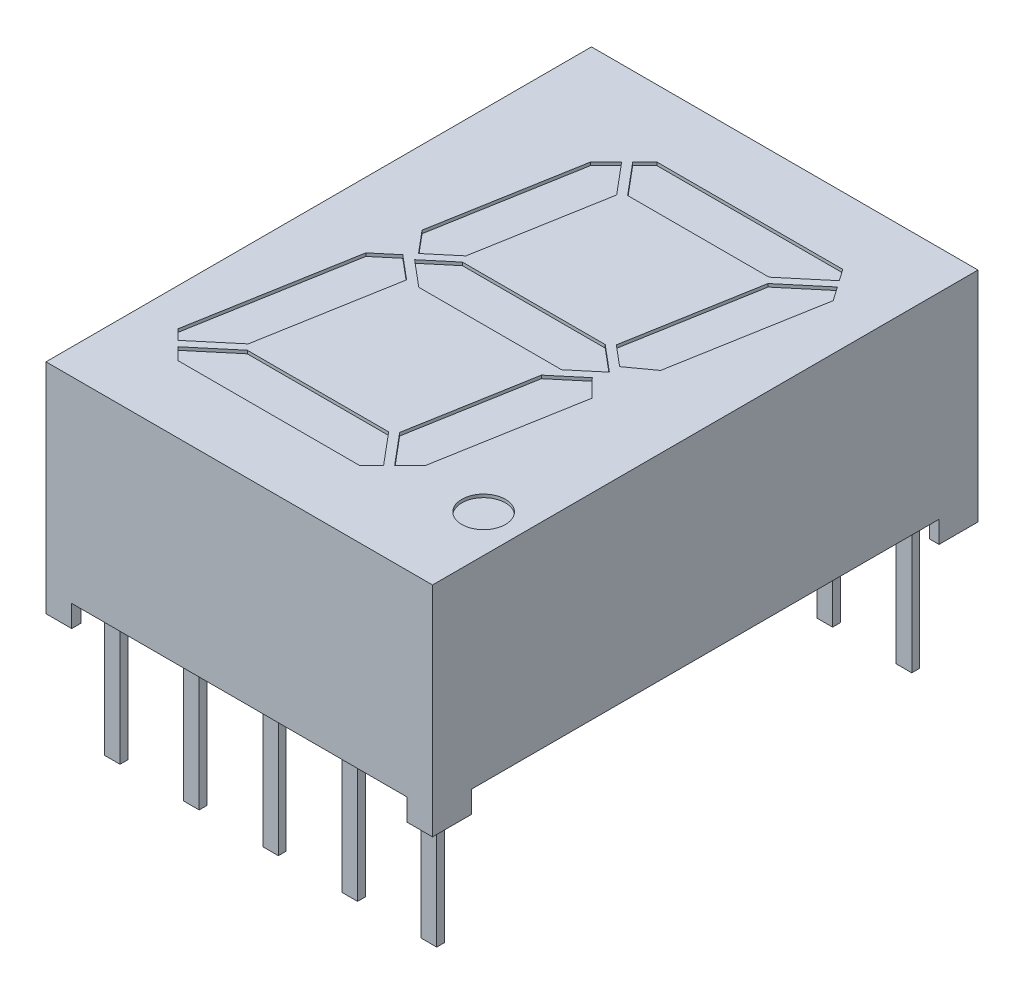
from build123d import *

# Parameters (mm, degrees)
SKETCH1_W          = 12.4
SKETCH1_H          = 17.5
EXTRUDE2_DEPTH     = 7
SKETCH2_W          = 5.375
SKETCH2_H          = 0.7
CUT_EXTRUDE2_DEPTH = 20.841622917
SKETCH3_W          = 15
SKETCH3_H          = 0.7
CUT_EXTRUDE3_DEPTH = 17.712944085
SKETCH6_R          = 0.7
CUT_EXTRUDE4_DEPTH = 0.1
SKETCH7_W          = 0.525
SKETCH7_H          = 0.95
CUT_EXTRUDE6_DEPTH = 0.7
SKETCH7_3_W        = 0.5
SKETCH7_3_H        = 0.25
EXTRUDE3_DEPTH     = 0.7
SKETCH7_4_W        = 0.525
SKETCH7_4_H        = 0.95
SKETCH7_4_W_2      = 0.5
SKETCH7_4_H_2      = 0.25
EXTRUDE4_DEPTH     = 4
SKETCH8_W          = 0.025316456
SKETCH8_H          = 0.026582279
CUT_EXTRUDE7_DEPTH = 0.01


with BuildPart() as part:
    # Sketch1 → Extrude2 (new body)
    with BuildSketch(Plane(origin=(0, 0, 0), x_dir=(1, 0, 0), z_dir=(0, 1, 0))):
        Rectangle(SKETCH1_W, SKETCH1_H)
    extrude(amount=-EXTRUDE2_DEPTH)

    # Sketch2 → Cut-Extrude2 (cut, through all)
    with BuildSketch(Plane.XY.offset(8.75)):
        with Locations((-2.6875, -6.65)):
            Rectangle(SKETCH2_W, SKETCH2_H)
        with Locations((2.6875, -6.65)):
            Rectangle(SKETCH2_W, SKETCH2_H)
    extrude(amount=-CUT_EXTRUDE2_DEPTH, mode=Mode.SUBTRACT)

    # Sketch3 → Cut-Extrude3 (cut, through all)
    with BuildSketch(Plane(origin=(6.2, 0, 0), x_dir=(0, 0, -1), z_dir=(1, 0, 0))):
        with Locations((0, -6.65)):
            Rectangle(SKETCH3_W, SKETCH3_H)
    extrude(amount=-CUT_EXTRUDE3_DEPTH, mode=Mode.SUBTRACT)

    # Sketch6 → Cut-Extrude4 (cut)
    with BuildSketch(Plane(origin=(0, 0, 0), x_dir=(-1, 0, 0), z_dir=(0, 1, 0))):
        Polygon((2.518570273, -6.036238766), (3.015469211, -5.539339828), (3.826241837, -0.941219775), (3.233742238, -0.23510625), (2.406800539, -0.928992725), (1.682041921, -5.039303098), align=None)
        Polygon((-4.011585774, -6.6), (1.954809039, -6.6), (2.341118319, -6.21369072), (1.49053081, -5.2), (-3.046184069, -5.2), (-4.271783106, -6.228399699), align=None)
        Polygon((3.45258656, 0.051474061), (4.096560254, 0.59183215), (5.000109846, 5.716116524), (4.679337781, 6.036888588), (3.453738745, 5.008488889), (2.692188648, 0.689523668), align=None)
        Polygon((-4.728556319, -5.576059945), (-4.415724957, -6.022829431), (-3.206880972, -5.008488889), (-2.477147485, -0.869964629), (-3.135471532, -0.317565164), (-3.898516777, -0.868671778), align=None)
        Polygon((2.290772485, -0.7), (3.125, 0), (2.290772485, 0.7), (-2.290772485, 0.7), (-3.125, 0), (-2.290772485, -0.7), align=None)
        Polygon((3.293041842, 5.2), (4.501885827, 6.214340542), (4.116226369, 6.6), (-1.707951266, 6.6), (-2.094260546, 6.21369072), (-1.243673037, 5.2), align=None)
        Polygon((-2.768611438, 5.539339828), (-3.567463069, 1.008827096), (-3.003440318, 0.428352507), (-2.117076363, 1.172100174), (-1.435184148, 5.039303098), (-2.2717125, 6.036238766), align=None)
        with Locations(Location((-4.989453029, 5.9, 0), (0, 0, 90))):
            Circle(SKETCH6_R)
    extrude(amount=-CUT_EXTRUDE4_DEPTH, mode=Mode.SUBTRACT)

    # Sketch7 → Cut-Extrude6 (cut)
    with BuildSketch(Plane.XZ.offset(7)):
        with Locations((-5.6375, 7.975)):
            Rectangle(SKETCH7_W, SKETCH7_H)
        with Locations((-5.6375, -7.975)):
            Rectangle(SKETCH7_W, SKETCH7_H)
        with Locations((5.6375, -7.975)):
            Rectangle(SKETCH7_W, SKETCH7_H)
        with Locations((5.6375, 7.975)):
            Rectangle(SKETCH7_W, SKETCH7_H)
    extrude(amount=-CUT_EXTRUDE6_DEPTH, mode=Mode.SUBTRACT)

    # Sketch7_3 → Extrude3 (add)
    with BuildSketch(Plane.XZ.offset(7)):
        with Locations((-5.08, 7.62)):
            Rectangle(SKETCH7_3_W, SKETCH7_3_H)
        with Locations((-2.54, 7.62)):
            Rectangle(SKETCH7_3_W, SKETCH7_3_H)
        with Locations((0, 7.62)):
            Rectangle(SKETCH7_3_W, SKETCH7_3_H)
        with Locations((2.54, 7.62)):
            Rectangle(SKETCH7_3_W, SKETCH7_3_H)
        with Locations((5.08, 7.62)):
            Rectangle(SKETCH7_3_W, SKETCH7_3_H)
        with Locations((5.08, -7.62)):
            Rectangle(SKETCH7_3_W, SKETCH7_3_H)
        with Locations((0, -7.62)):
            Rectangle(SKETCH7_3_W, SKETCH7_3_H)
        with Locations((2.54, -7.62)):
            Rectangle(SKETCH7_3_W, SKETCH7_3_H)
        with Locations((-2.54, -7.62)):
            Rectangle(SKETCH7_3_W, SKETCH7_3_H)
        with Locations((-5.08, -7.62)):
            Rectangle(SKETCH7_3_W, SKETCH7_3_H)
    extrude(amount=-EXTRUDE3_DEPTH)


with BuildPart() as extrude4_tool:
    # Sketch7_4 → Extrude4 (new body)
    with BuildSketch(Plane.XZ.offset(7)):
        with Locations((-5.6375, 7.975)):
            Rectangle(SKETCH7_4_W, SKETCH7_4_H)
        with Locations((-5.6375, -7.975)):
            Rectangle(SKETCH7_4_W, SKETCH7_4_H)
        with Locations((5.6375, -7.975)):
            Rectangle(SKETCH7_4_W, SKETCH7_4_H)
        with Locations((5.6375, 7.975)):
            Rectangle(SKETCH7_4_W, SKETCH7_4_H)
        with Locations((-5.08, 7.62)):
            Rectangle(SKETCH7_4_W_2, SKETCH7_4_H_2)
        with Locations((-2.54, 7.62)):
            Rectangle(SKETCH7_4_W_2, SKETCH7_4_H_2)
        with Locations((0, 7.62)):
            Rectangle(SKETCH7_4_W_2, SKETCH7_4_H_2)
        with Locations((2.54, 7.62)):
            Rectangle(SKETCH7_4_W_2, SKETCH7_4_H_2)
        with Locations((5.08, 7.62)):
            Rectangle(SKETCH7_4_W_2, SKETCH7_4_H_2)
        with Locations((5.08, -7.62)):
            Rectangle(SKETCH7_4_W_2, SKETCH7_4_H_2)
        with Locations((0, -7.62)):
            Rectangle(SKETCH7_4_W_2, SKETCH7_4_H_2)
        with Locations((2.54, -7.62)):
            Rectangle(SKETCH7_4_W_2, SKETCH7_4_H_2)
        with Locations((-2.54, -7.62)):
            Rectangle(SKETCH7_4_W_2, SKETCH7_4_H_2)
        with Locations((-5.08, -7.62)):
            Rectangle(SKETCH7_4_W_2, SKETCH7_4_H_2)
    extrude(amount=EXTRUDE4_DEPTH)


with BuildPart() as part_1:
    add(part.part)


with BuildPart() as part_2:
    # Extrude4: joined with extrude4_tool
    add(part_1.part.fuse(extrude4_tool.part, tol=0.00001))


with BuildPart() as extrude4_kept_piece:
    # of the separate pieces the step leaves, the one the design keeps (extrude4_pieces_kept)
    add(part_2.part.solids().sort_by_distance((-6.2, 0, -8.75))[0])

    # Sketch8 → Cut-Extrude7 (cut)
    with BuildSketch(Plane.XZ.offset(6.3)):
        Polygon((-0.572151899, -6.278449642), (-0.595609177, -6.353133186), (-0.620352057, -6.353133186), (-0.636768196, -6.302796952), (-0.652294304, -6.353133186), (-0.678026108, -6.353133186), (-0.701265823, -6.278449642), (-0.676087816, -6.278449642), (-0.663093354, -6.329933028), (-0.646677215, -6.278449642), (-0.625178006, -6.278449642), (-0.608860759, -6.329933028), (-0.596044304, -6.278449642), align=None)
        Polygon((-0.437974684, -6.278449642), (-0.461431962, -6.353133186), (-0.486174842, -6.353133186), (-0.502590981, -6.302796952), (-0.518117089, -6.353133186), (-0.543848892, -6.353133186), (-0.567088608, -6.278449642), (-0.541910601, -6.278449642), (-0.528916139, -6.329933028), (-0.5125, -6.278449642), (-0.491000791, -6.278449642), (-0.474683544, -6.329933028), (-0.461867089, -6.278449642), align=None)
        Polygon((-0.303797468, -6.278449642), (-0.327254747, -6.353133186), (-0.351997627, -6.353133186), (-0.368413766, -6.302796952), (-0.383939873, -6.353133186), (-0.409671677, -6.353133186), (-0.432911392, -6.278449642), (-0.407733386, -6.278449642), (-0.394738924, -6.329933028), (-0.378322785, -6.278449642), (-0.356823576, -6.278449642), (-0.340506329, -6.329933028), (-0.327689873, -6.278449642), align=None)
        with Locations((-0.275949367, -6.339842047)):
            Rectangle(SKETCH8_W, SKETCH8_H)
        with BuildLine():
            add(Edge.make_bspline(
                [(-0.159493671, -6.3219623), (-0.15953016, -6.323184441), (-0.159601812, -6.325584319), (-0.16021153, -6.329091898), (-0.161205016, -6.332416603), (-0.162579134, -6.335579263), (-0.164367936, -6.338557882), (-0.166577526, -6.341338159), (-0.169141939, -6.343972959), (-0.172108149, -6.346379089), (-0.175388259, -6.348583466), (-0.178985835, -6.350480465), (-0.182864539, -6.352076948), (-0.187013125, -6.353415499), (-0.191459564, -6.35440408), (-0.196177094, -6.355128025), (-0.201170512, -6.355601355), (-0.20459409, -6.355643321), (-0.206348892, -6.355664831)],
                knots=[0, 0, 0, 0, 0.907352243, 1.781736951, 2.63548328, 3.47985091, 4.336556021, 5.208523475, 6.112432747, 7.062451073, 8.040435374, 9.043840564, 10.077958095, 11.152835584, 12.277940427, 13.457536469, 14.696825396, 16, 16, 16, 16], degree=3))
            add(Edge.make_bspline(
                [(-0.206348892, -6.355664831), (-0.208367148, -6.35564076), (-0.21227633, -6.355594135), (-0.217939855, -6.355165536), (-0.223207892, -6.354519396), (-0.228103607, -6.353552855), (-0.232708206, -6.35235209), (-0.237141474, -6.351060798), (-0.241422786, -6.349596382), (-0.244195876, -6.348496225), (-0.24556962, -6.347951224)],
                knots=[0, 0, 0, 0, 1.203215828, 2.33052265, 3.384689099, 4.366106119, 5.303329643, 6.221311756, 7.118865988, 8, 8, 8, 8], degree=3))
            Line((-0.24556962, -6.347951224), (-0.24556962, -6.324019262))
            Line((-0.24556962, -6.324019262), (-0.242721519, -6.324019262))
            add(Edge.make_bspline(
                [(-0.242721519, -6.324019262), (-0.241356205, -6.325100717), (-0.238633592, -6.327257278), (-0.234200359, -6.330019883), (-0.229552713, -6.332422046), (-0.224707243, -6.334396048), (-0.219810398, -6.335982372), (-0.21493502, -6.337075899), (-0.210169433, -6.337823248), (-0.207010864, -6.337903755), (-0.205458861, -6.337943312)],
                knots=[0, 0, 0, 0, 1.030622468, 2.055194264, 3.087043286, 4.125157485, 5.149848264, 6.130935704, 7.081611712, 8, 8, 8, 8], degree=3))
            add(Edge.make_bspline(
                [(-0.205458861, -6.337943312), (-0.205030085, -6.337942389), (-0.204112108, -6.337940412), (-0.202650581, -6.337812684), (-0.20099877, -6.337717108), (-0.199226261, -6.337509923), (-0.197429535, -6.337288063), (-0.195767134, -6.336913138), (-0.194257539, -6.33654827), (-0.193351018, -6.336180273), (-0.192919304, -6.336005021)],
                knots=[0, 0, 0, 0, 0.806402781, 1.726445712, 2.758724871, 3.919014682, 5.083870887, 6.16165551, 7.124521387, 8, 8, 8, 8], degree=3))
            add(Edge.make_bspline(
                [(-0.192919304, -6.336005021), (-0.192439741, -6.335776879), (-0.191497298, -6.335328532), (-0.190203698, -6.334518214), (-0.189036018, -6.333634749), (-0.187978647, -6.332669818), (-0.187104366, -6.331504068), (-0.186480499, -6.330095395), (-0.186135606, -6.328446377), (-0.186096583, -6.327271174), (-0.186075949, -6.3266498)],
                knots=[0, 0, 0, 0, 1.024747072, 2.013846092, 2.940605744, 3.850156746, 4.769278501, 5.73222711, 6.800942666, 8, 8, 8, 8], degree=3))
            add(Edge.make_bspline(
                [(-0.186075949, -6.3266498), (-0.186107794, -6.326104162), (-0.18617041, -6.325031279), (-0.186747603, -6.323496164), (-0.187657041, -6.322086996), (-0.188938631, -6.320818221), (-0.190531807, -6.319668688), (-0.192474191, -6.318686382), (-0.194724312, -6.317813195), (-0.196368382, -6.317395217), (-0.197231013, -6.317175907)],
                knots=[0, 0, 0, 0, 0.82557554, 1.623324704, 2.456147571, 3.35491006, 4.343819762, 5.427079081, 6.650009487, 8, 8, 8, 8], degree=3))
            add(Edge.make_bspline(
                [(-0.197231013, -6.317175907), (-0.199199639, -6.316727667), (-0.203238649, -6.315808017), (-0.209388473, -6.314669263), (-0.215516824, -6.313394403), (-0.219469591, -6.31218776), (-0.221400316, -6.311598376)],
                knots=[0, 0, 0, 0, 0.976100998, 2.002656142, 3.024398856, 4, 4, 4, 4], degree=3))
            add(Edge.make_bspline(
                [(-0.221400316, -6.311598376), (-0.222438835, -6.311245386), (-0.224460408, -6.310558258), (-0.227351919, -6.309396597), (-0.230013147, -6.308126768), (-0.23245286, -6.306771213), (-0.234653549, -6.305298673), (-0.236647817, -6.303757295), (-0.238410933, -6.302117256), (-0.239957738, -6.300377489), (-0.241282641, -6.298526787), (-0.242435025, -6.296581589), (-0.243417646, -6.294526169), (-0.244195684, -6.292355947), (-0.244820323, -6.290082291), (-0.245239305, -6.287704579), (-0.245538322, -6.28522145), (-0.245559046, -6.283527065), (-0.24556962, -6.282662458)],
                knots=[0, 0, 0, 0, 1.287047841, 2.5053592, 3.654260482, 4.74538952, 5.777514103, 6.75871007, 7.700244599, 8.599107454, 9.48590269, 10.366941872, 11.24940663, 12.154970331, 13.068988358, 14.012872203, 14.986013017, 16, 16, 16, 16], degree=3))
            add(Edge.make_bspline(
                [(-0.24556962, -6.282662458), (-0.245532318, -6.281506313), (-0.245458909, -6.279231041), (-0.24485748, -6.275901997), (-0.24383089, -6.27275326), (-0.242444827, -6.269749797), (-0.240616199, -6.266936711), (-0.238431404, -6.264258164), (-0.235807357, -6.261786572), (-0.232830235, -6.259486238), (-0.229542851, -6.25740684), (-0.226003867, -6.255576284), (-0.222234578, -6.254039632), (-0.218249032, -6.252765738), (-0.214030563, -6.251811067), (-0.20959333, -6.251092136), (-0.204919541, -6.250678954), (-0.20172812, -6.250627704), (-0.200098892, -6.25060154)],
                knots=[0, 0, 0, 0, 0.894990994, 1.761326291, 2.609044902, 3.454222546, 4.315366365, 5.200560057, 6.125081389, 7.100429509, 8.110379559, 9.133447974, 10.182136699, 11.259192205, 12.370181258, 13.528580438, 14.738335141, 16, 16, 16, 16], degree=3))
            add(Edge.make_bspline(
                [(-0.200098892, -6.25060154), (-0.198430198, -6.250623693), (-0.19509564, -6.250667961), (-0.1901143, -6.251046518), (-0.185159872, -6.25159883), (-0.180297448, -6.25244807), (-0.175605285, -6.253416302), (-0.17118617, -6.254515575), (-0.167106618, -6.255753082), (-0.164532965, -6.256707483), (-0.163291139, -6.257167996)],
                knots=[0, 0, 0, 0, 1.065407564, 2.129008667, 3.188544425, 4.247469455, 5.279542408, 6.247502114, 7.154394069, 8, 8, 8, 8], degree=3))
            Line((-0.163291139, -6.257167996), (-0.163291139, -6.279715464))
            Line((-0.163291139, -6.279715464), (-0.166119462, -6.279715464))
            add(Edge.make_bspline(
                [(-0.166119462, -6.279715464), (-0.167192966, -6.278916177), (-0.169383743, -6.277285011), (-0.173033347, -6.275183275), (-0.177000967, -6.273243184), (-0.181282594, -6.271551527), (-0.185742374, -6.27009352), (-0.190325133, -6.269073962), (-0.194951348, -6.268432254), (-0.198053052, -6.268359466), (-0.19960443, -6.268323059)],
                knots=[0, 0, 0, 0, 0.892265782, 1.820912499, 2.804518821, 3.836954028, 4.889985052, 5.931488012, 6.965393252, 8, 8, 8, 8], degree=3))
            add(Edge.make_bspline(
                [(-0.19960443, -6.268323059), (-0.200700035, -6.268344962), (-0.202897679, -6.268388896), (-0.20616687, -6.268773782), (-0.209407348, -6.269412634), (-0.21144203, -6.270228686), (-0.212460443, -6.270637142)],
                knots=[0, 0, 0, 0, 0.999122297, 2.004111588, 3.001004448, 4, 4, 4, 4], degree=3))
            add(Edge.make_bspline(
                [(-0.212460443, -6.270637142), (-0.212894173, -6.270838321), (-0.213761342, -6.271240544), (-0.214968884, -6.27202017), (-0.216089856, -6.272936513), (-0.217085439, -6.27398927), (-0.217929873, -6.275157624), (-0.218548899, -6.276425207), (-0.218923392, -6.277789088), (-0.218965739, -6.278724187), (-0.218987342, -6.279201224)],
                knots=[0, 0, 0, 0, 1.004925302, 2.009180302, 3.014392739, 4.04465309, 5.049195417, 6.035570224, 6.99785458, 8, 8, 8, 8], degree=3))
            add(Edge.make_bspline(
                [(-0.218987342, -6.279201224), (-0.218952904, -6.279839389), (-0.218887095, -6.281058865), (-0.218280511, -6.282774661), (-0.217295678, -6.284253095), (-0.216135073, -6.285248015), (-0.215017943, -6.285945453), (-0.213982284, -6.286455963), (-0.212773057, -6.286939322), (-0.211401809, -6.287436791), (-0.209865482, -6.287927978), (-0.208156925, -6.288403525), (-0.206274208, -6.288852821), (-0.204958333, -6.289139011), (-0.204272152, -6.289288249)],
                knots=[0, 0, 0, 0, 1.173816843, 2.243057204, 3.312297565, 4.415174738, 5.03266065, 5.73970059, 6.541434878, 7.433956553, 8.430083051, 9.515931566, 10.70464786, 12, 12, 12, 12], degree=3))
            add(Edge.make_bspline(
                [(-0.204272152, -6.289288249), (-0.202439229, -6.289663694), (-0.198844263, -6.290400065), (-0.193445039, -6.29151243), (-0.187940051, -6.292777789), (-0.184268899, -6.293929785), (-0.182357595, -6.294529547)],
                knots=[0, 0, 0, 0, 0.995749986, 1.952994291, 2.934271555, 4, 4, 4, 4], degree=3))
            add(Edge.make_bspline(
                [(-0.182357595, -6.294529547), (-0.181411107, -6.294848906), (-0.179559623, -6.295473623), (-0.176918075, -6.296558307), (-0.174469022, -6.297740397), (-0.172190751, -6.298962883), (-0.17012867, -6.300326099), (-0.168235447, -6.301740747), (-0.166552428, -6.303268855), (-0.165054478, -6.304881714), (-0.163736077, -6.306592146), (-0.162601114, -6.308430248), (-0.161637968, -6.310384777), (-0.160829836, -6.312457849), (-0.16025182, -6.314664917), (-0.159817762, -6.316991218), (-0.15952694, -6.319436533), (-0.159504884, -6.32111098), (-0.159493671, -6.3219623)],
                knots=[0, 0, 0, 0, 1.237386967, 2.420528625, 3.534815053, 4.605870898, 5.620827102, 6.594482803, 7.531295079, 8.432978826, 9.318460435, 10.202471551, 11.10474705, 12.014900263, 12.954095338, 13.926516828, 14.945802342, 16, 16, 16, 16], degree=3))
        make_face()
        with BuildLine():
            Line((-0.067088608, -6.353133186), (-0.091139241, -6.353133186))
            Line((-0.091139241, -6.353133186), (-0.091139241, -6.345300907))
            add(Edge.make_bspline(
                [(-0.091139241, -6.345300907), (-0.092232496, -6.346109575), (-0.094340276, -6.347668673), (-0.097514015, -6.349747438), (-0.100542736, -6.351530599), (-0.103464337, -6.353072752), (-0.106479693, -6.354263599), (-0.109707195, -6.355085455), (-0.113209459, -6.355586575), (-0.115636434, -6.355638166), (-0.116890823, -6.355664831)],
                knots=[0, 0, 0, 0, 1.150906677, 2.218931226, 3.20955724, 4.125565256, 5.012676028, 5.946647191, 6.938718366, 8, 8, 8, 8], degree=3))
            add(Edge.make_bspline(
                [(-0.116890823, -6.355664831), (-0.117907168, -6.355642102), (-0.119886286, -6.355597842), (-0.122763616, -6.355253104), (-0.125470927, -6.354714958), (-0.127987077, -6.353909102), (-0.130352422, -6.352934986), (-0.132503941, -6.351675898), (-0.13449163, -6.350216561), (-0.136295007, -6.348539626), (-0.137885627, -6.346618664), (-0.139272677, -6.344495913), (-0.140448489, -6.342161274), (-0.141390127, -6.339609907), (-0.142145061, -6.336851463), (-0.142669038, -6.333872256), (-0.142989618, -6.330685117), (-0.143021559, -6.328489988), (-0.143037975, -6.327361825)],
                knots=[0, 0, 0, 0, 1.108935798, 2.159418225, 3.158520219, 4.116592843, 5.038730546, 5.944611115, 6.829677354, 7.725673622, 8.624842385, 9.544872214, 10.487719724, 11.471363217, 12.50822837, 13.604887271, 14.769056852, 16, 16, 16, 16], degree=3))
            Line((-0.143037975, -6.327361825), (-0.143037975, -6.278449642))
            Line((-0.143037975, -6.278449642), (-0.118987342, -6.278449642))
            Line((-0.118987342, -6.278449642), (-0.118987342, -6.316028755))
            add(Edge.make_bspline(
                [(-0.118987342, -6.316028755), (-0.118985706, -6.316945226), (-0.118982576, -6.318699442), (-0.118900237, -6.321205249), (-0.118779336, -6.323473421), (-0.118640631, -6.32551545), (-0.118387615, -6.327362201), (-0.118009906, -6.329028362), (-0.11753908, -6.330547963), (-0.117074761, -6.331454665), (-0.116851266, -6.331891097)],
                knots=[0, 0, 0, 0, 1.361401701, 2.605856924, 3.723918663, 4.735739235, 5.645738665, 6.489217889, 7.27279937, 8, 8, 8, 8], degree=3))
            add(Edge.make_bspline(
                [(-0.116851266, -6.331891097), (-0.116621226, -6.332289745), (-0.116168987, -6.333073452), (-0.115249176, -6.3340806), (-0.114173193, -6.334917507), (-0.112903555, -6.335590151), (-0.111410474, -6.336073854), (-0.109678473, -6.336420601), (-0.107692458, -6.336634425), (-0.106283538, -6.336662587), (-0.105537975, -6.33667749)],
                knots=[0, 0, 0, 0, 0.849057291, 1.669173542, 2.503217716, 3.359509317, 4.311793648, 5.394940091, 6.621469141, 8, 8, 8, 8], degree=3))
            add(Edge.make_bspline(
                [(-0.105537975, -6.33667749), (-0.10499671, -6.336660032), (-0.103883832, -6.336624139), (-0.102178621, -6.33639421), (-0.100389592, -6.336032554), (-0.097875395, -6.33537353), (-0.09469925, -6.334194352), (-0.092335111, -6.33283555), (-0.091139241, -6.332148218)],
                knots=[0, 0, 0, 0, 0.638164724, 1.312110757, 2.025558264, 2.789159289, 4.375836335, 6, 6, 6, 6], degree=3))
            Line((-0.091139241, -6.332148218), (-0.091139241, -6.278449642))
            Line((-0.091139241, -6.278449642), (-0.067088608, -6.278449642))
            Line((-0.067088608, -6.278449642), (-0.067088608, -6.353133186))
        make_face()
        with BuildLine():
            Line((0.030379747, -6.353133186), (0.006329114, -6.353133186))
            Line((0.006329114, -6.353133186), (0.006329114, -6.315554072))
            add(Edge.make_bspline(
                [(0.006329114, -6.315554072), (0.00630879, -6.314023599), (0.006268255, -6.310971186), (0.005934675, -6.307214411), (0.005600966, -6.30436662), (0.005224143, -6.302530553), (0.004793956, -6.300982217), (0.00438151, -6.300096479), (0.004193038, -6.29969173)],
                knots=[0, 0, 0, 0, 1.709235885, 3.408940626, 4.211008593, 4.910095588, 5.501954032, 6, 6, 6, 6], degree=3))
            add(Edge.make_bspline(
                [(0.004193038, -6.29969173), (0.00394861, -6.299293608), (0.003469373, -6.298513033), (0.002531558, -6.297501011), (0.001434909, -6.296664797), (0.000156185, -6.295999847), (-0.001328468, -6.295513949), (-0.003041142, -6.29512729), (-0.005027113, -6.29495873), (-0.006434481, -6.29492382), (-0.007179589, -6.294905338)],
                knots=[0, 0, 0, 0, 0.860145871, 1.686437142, 2.528070002, 3.393017362, 4.331453407, 5.402595683, 6.624848233, 8, 8, 8, 8], degree=3))
            add(Edge.make_bspline(
                [(-0.007179589, -6.294905338), (-0.008311478, -6.294961918), (-0.010622712, -6.295077451), (-0.013484003, -6.295791043), (-0.015810878, -6.29660334), (-0.017656499, -6.297377577), (-0.019573028, -6.298332202), (-0.020856452, -6.299059276), (-0.021518987, -6.29943461)],
                knots=[0, 0, 0, 0, 1.338419466, 2.732951426, 3.468143565, 4.254837763, 5.099104234, 6, 6, 6, 6], degree=3))
            Line((-0.021518987, -6.29943461), (-0.021518987, -6.353133186))
            Line((-0.021518987, -6.353133186), (-0.04556962, -6.353133186))
            Line((-0.04556962, -6.353133186), (-0.04556962, -6.278449642))
            Line((-0.04556962, -6.278449642), (-0.021518987, -6.278449642))
            Line((-0.021518987, -6.278449642), (-0.021518987, -6.28628192))
            add(Edge.make_bspline(
                [(-0.021518987, -6.28628192), (-0.02046175, -6.285475482), (-0.018403774, -6.283905703), (-0.015227022, -6.281872294), (-0.01215631, -6.280062437), (-0.009101788, -6.278550303), (-0.005977291, -6.277351703), (-0.00270966, -6.2765361), (0.000707053, -6.275993151), (0.003043726, -6.27594334), (0.004232595, -6.275917996)],
                knots=[0, 0, 0, 0, 1.126064518, 2.191951536, 3.19307265, 4.144813015, 5.076393104, 6.021983703, 6.993610568, 8, 8, 8, 8], degree=3))
            add(Edge.make_bspline(
                [(0.004232595, -6.275917996), (0.005228866, -6.275943385), (0.007173765, -6.275992949), (0.010008526, -6.276302658), (0.012679947, -6.276853323), (0.015172222, -6.277651152), (0.017514838, -6.278636765), (0.019676795, -6.279868276), (0.021668821, -6.281326715), (0.02349739, -6.282987656), (0.025127571, -6.284877615), (0.026547057, -6.286993988), (0.02771848, -6.289342716), (0.028727312, -6.291889853), (0.029461537, -6.294667623), (0.029987988, -6.297658389), (0.030338418, -6.300863571), (0.030365695, -6.303079471), (0.030379747, -6.304221002)],
                knots=[0, 0, 0, 0, 1.088441561, 2.124831547, 3.110816719, 4.062969431, 4.979391633, 5.88258537, 6.774334107, 7.671621258, 8.575503974, 9.49441354, 10.447872957, 11.437639084, 12.482478955, 13.580222388, 14.753440527, 16, 16, 16, 16], degree=3))
            Line((0.030379747, -6.304221002), (0.030379747, -6.353133186))
        make_face()
        Polygon((0.125316456, -6.353133186), (0.053164557, -6.353133186), (0.053164557, -6.253133186), (0.078481013, -6.253133186), (0.078481013, -6.334145844), (0.125316456, -6.334145844), align=None)
        Polygon((0.212658228, -6.353133186), (0.140506329, -6.353133186), (0.140506329, -6.253133186), (0.212658228, -6.253133186), (0.212658228, -6.272120528), (0.165822785, -6.272120528), (0.165822785, -6.289842047), (0.208860759, -6.289842047), (0.208860759, -6.308829388), (0.165822785, -6.308829388), (0.165822785, -6.334145844), (0.212658228, -6.334145844), align=None)
        with BuildLine():
            add(Edge.make_bspline(
                [(0.329113924, -6.303232078), (0.329094609, -6.304379767), (0.329056357, -6.306652653), (0.328761165, -6.31001746), (0.32823514, -6.313283135), (0.327555959, -6.316467384), (0.326633453, -6.319546312), (0.325551739, -6.322553889), (0.324242093, -6.325459382), (0.322737241, -6.328260817), (0.321087768, -6.330932919), (0.319313019, -6.333453128), (0.31746724, -6.335836346), (0.315477927, -6.33803124), (0.313398746, -6.340073259), (0.311223217, -6.341964074), (0.308918153, -6.343667504), (0.30731099, -6.344690389), (0.30650712, -6.345202015)],
                knots=[0, 0, 0, 0, 1.105570398, 2.18947457, 3.250358341, 4.290584537, 5.323553275, 6.344225964, 7.367641686, 8.3905646, 9.405808457, 10.390761353, 11.358902336, 12.307789878, 13.241960776, 14.165076779, 15.082208636, 16, 16, 16, 16], degree=3))
            add(Edge.make_bspline(
                [(0.30650712, -6.345202015), (0.305267899, -6.345914185), (0.302783134, -6.347342158), (0.298799188, -6.349010289), (0.294668069, -6.350418245), (0.290309515, -6.351466435), (0.285663167, -6.352195168), (0.28066851, -6.352758219), (0.275267382, -6.353058583), (0.2715325, -6.353107751), (0.269600475, -6.353133186)],
                knots=[0, 0, 0, 0, 0.896298978, 1.797171328, 2.70531317, 3.633678302, 4.606491125, 5.655688921, 6.787306437, 8, 8, 8, 8], degree=3))
            Line((0.269600475, -6.353133186), (0.234177215, -6.353133186))
            Line((0.234177215, -6.353133186), (0.234177215, -6.253133186))
            Line((0.234177215, -6.253133186), (0.270609177, -6.253133186))
            add(Edge.make_bspline(
                [(0.270609177, -6.253133186), (0.272587901, -6.253149881), (0.276404614, -6.253182085), (0.281915032, -6.253598053), (0.287013411, -6.254197573), (0.291697991, -6.255124265), (0.296006397, -6.256232916), (0.299937419, -6.257595952), (0.303549308, -6.259094223), (0.305728136, -6.260367971), (0.306784019, -6.260985243)],
                knots=[0, 0, 0, 0, 1.267192274, 2.444256634, 3.537982003, 4.553396635, 5.500903572, 6.385021601, 7.217363933, 8, 8, 8, 8], degree=3))
            add(Edge.make_bspline(
                [(0.306784019, -6.260985243), (0.307634972, -6.261521783), (0.309327097, -6.262588697), (0.311728312, -6.264370549), (0.313957739, -6.266326626), (0.316086242, -6.268378445), (0.318066056, -6.270581332), (0.319909269, -6.272920036), (0.321613036, -6.275398143), (0.323171192, -6.278007563), (0.324591277, -6.280737803), (0.325783356, -6.283610148), (0.326822718, -6.286593021), (0.327668801, -6.289691961), (0.32832513, -6.29290935), (0.328771214, -6.29624683), (0.329054647, -6.299700019), (0.329093999, -6.302044812), (0.329113924, -6.303232078)],
                knots=[0, 0, 0, 0, 0.964043478, 1.917004671, 2.862223898, 3.805158963, 4.749279098, 5.698713747, 6.657523689, 7.629652222, 8.610369353, 9.604453025, 10.607693792, 11.636365947, 12.681120053, 13.752669011, 14.862083412, 16, 16, 16, 16], degree=3))
        make_face()
        with BuildLine():
            add(Edge.make_bspline(
                [(0.302531646, -6.30307385), (0.302521175, -6.302269137), (0.302500636, -6.300690645), (0.302312313, -6.29837447), (0.302041725, -6.29614842), (0.301652591, -6.294004787), (0.301112159, -6.29195464), (0.300479977, -6.28999307), (0.299752887, -6.288114147), (0.298871957, -6.286336487), (0.297898133, -6.28462815), (0.296750689, -6.283042623), (0.295502338, -6.28152974), (0.294124055, -6.280101754), (0.292581114, -6.278795859), (0.290921012, -6.277565782), (0.289120654, -6.276437457), (0.287847665, -6.275777407), (0.287203323, -6.275443312)],
                knots=[0, 0, 0, 0, 1.152052275, 2.259818351, 3.325348653, 4.362224493, 5.376551665, 6.358740615, 7.312387502, 8.258104984, 9.197203025, 10.124507262, 11.056413058, 12.004389423, 12.961766972, 13.947352551, 14.961020569, 16, 16, 16, 16], degree=3))
            add(Edge.make_bspline(
                [(0.287203323, -6.275443312), (0.286528425, -6.2751366), (0.285190731, -6.274528676), (0.283119908, -6.273797484), (0.281030524, -6.273224648), (0.278828925, -6.27279379), (0.276359165, -6.272471859), (0.273433583, -6.2722746), (0.269977674, -6.272132431), (0.267490959, -6.272124679), (0.266159019, -6.272120528)],
                knots=[0, 0, 0, 0, 0.826967603, 1.639107464, 2.447640171, 3.242670507, 4.14065217, 5.225198036, 6.513753944, 8, 8, 8, 8], degree=3))
            Line((0.266159019, -6.272120528), (0.259493671, -6.272120528))
            Line((0.259493671, -6.272120528), (0.259493671, -6.334145844))
            Line((0.259493671, -6.334145844), (0.266159019, -6.334145844))
            add(Edge.make_bspline(
                [(0.266159019, -6.334145844), (0.266917226, -6.334141098), (0.268380993, -6.334131936), (0.27049723, -6.334088823), (0.272463046, -6.334042109), (0.274267852, -6.333925071), (0.275920195, -6.333854572), (0.277406342, -6.333670901), (0.278743292, -6.333536425), (0.280315773, -6.333258703), (0.28217096, -6.332852728), (0.284337749, -6.33216957), (0.286478448, -6.331319996), (0.287866999, -6.330634917), (0.288568038, -6.33028904)],
                knots=[0, 0, 0, 0, 1.186805873, 2.291202465, 3.313317863, 4.264127762, 5.122212376, 5.900577546, 6.607154111, 7.224697658, 8.398873738, 9.57716935, 10.776782771, 12, 12, 12, 12], degree=3))
            add(Edge.make_bspline(
                [(0.288568038, -6.33028904), (0.289153152, -6.329947523), (0.290307072, -6.329274005), (0.291930612, -6.328139954), (0.293438202, -6.326932144), (0.294834679, -6.325644004), (0.296096265, -6.324254618), (0.297252353, -6.322795152), (0.29825774, -6.321234831), (0.299496994, -6.319046005), (0.300744084, -6.316021248), (0.301776483, -6.312048494), (0.302415631, -6.307689582), (0.302491983, -6.304651841), (0.302531646, -6.30307385)],
                knots=[0, 0, 0, 0, 0.755237594, 1.489427721, 2.205882609, 2.908165467, 3.605466573, 4.296695275, 4.981837198, 5.673065901, 7.099889822, 8.61390339, 10.241051878, 12, 12, 12, 12], degree=3))
        make_face(mode=Mode.SUBTRACT)
        with Locations((0.360759494, -6.339842047)):
            Rectangle(SKETCH8_W, SKETCH8_H)
        with BuildLine():
            add(Edge.make_bspline(
                [(0.435403481, -6.355664831), (0.433813364, -6.355643028), (0.43069222, -6.355600232), (0.426120933, -6.355123204), (0.421755567, -6.354405907), (0.417609943, -6.353383588), (0.4136994, -6.352043069), (0.41004445, -6.350373063), (0.406627778, -6.348405867), (0.404565858, -6.346820971), (0.403540348, -6.346032711)],
                knots=[0, 0, 0, 0, 1.123701398, 2.205645569, 3.245398653, 4.249180969, 5.220497262, 6.163202923, 7.086456062, 8, 8, 8, 8], degree=3))
            add(Edge.make_bspline(
                [(0.403540348, -6.346032711), (0.402588713, -6.345177878), (0.400689124, -6.343471518), (0.398221497, -6.340500974), (0.396103421, -6.337212001), (0.394291165, -6.333620348), (0.392859214, -6.329700463), (0.391866679, -6.325450569), (0.391239075, -6.320893239), (0.391173123, -6.317745035), (0.391139241, -6.316127648)],
                knots=[0, 0, 0, 0, 0.916342154, 1.829140869, 2.758848968, 3.716597128, 4.708179637, 5.743612459, 6.840783343, 8, 8, 8, 8], degree=3))
            add(Edge.make_bspline(
                [(0.391139241, -6.316127648), (0.391178001, -6.314424421), (0.391253124, -6.311123341), (0.391916883, -6.306351153), (0.392986496, -6.301933473), (0.394524054, -6.297881564), (0.396454496, -6.294188373), (0.398718989, -6.290816538), (0.401339514, -6.287773614), (0.403346653, -6.286028174), (0.404351266, -6.285154547)],
                knots=[0, 0, 0, 0, 1.171797512, 2.271099083, 3.308930235, 4.294129479, 5.24602549, 6.17106565, 7.084581485, 8, 8, 8, 8], degree=3))
            add(Edge.make_bspline(
                [(0.404351266, -6.285154547), (0.40537705, -6.284385768), (0.407441008, -6.282838925), (0.410840547, -6.280944112), (0.41445276, -6.279339595), (0.418283877, -6.278093709), (0.422264395, -6.277145172), (0.426329936, -6.2764182), (0.430476303, -6.275998175), (0.433266488, -6.275944851), (0.434671677, -6.275917996)],
                knots=[0, 0, 0, 0, 0.952097844, 1.915695341, 2.885641886, 3.886921822, 4.905719434, 5.925883802, 6.95543633, 8, 8, 8, 8], degree=3))
            add(Edge.make_bspline(
                [(0.434671677, -6.275917996), (0.435918404, -6.27593496), (0.438369891, -6.275968316), (0.441970824, -6.276290973), (0.445419409, -6.276821138), (0.448716721, -6.277564732), (0.451889869, -6.27845753), (0.454949341, -6.279488811), (0.457914157, -6.280626752), (0.459814835, -6.281510968), (0.460759494, -6.281950433)],
                knots=[0, 0, 0, 0, 1.107671842, 2.178058178, 3.209662749, 4.206063564, 5.179815947, 6.137646632, 7.07438927, 8, 8, 8, 8], degree=3))
            Line((0.460759494, -6.281950433), (0.460759494, -6.302500274))
            Line((0.460759494, -6.302500274), (0.45741693, -6.302500274))
            add(Edge.make_bspline(
                [(0.45741693, -6.302500274), (0.456918162, -6.302082047), (0.455836226, -6.301174824), (0.454034874, -6.299773811), (0.451901363, -6.298223245), (0.450250156, -6.297337242), (0.449367089, -6.296863407)],
                knots=[0, 0, 0, 0, 0.792878214, 1.719922066, 2.780612869, 4, 4, 4, 4], degree=3))
            add(Edge.make_bspline(
                [(0.449367089, -6.296863407), (0.448439429, -6.296420539), (0.4465324, -6.295510115), (0.443972423, -6.294690572), (0.441783392, -6.294112035), (0.439971509, -6.293859225), (0.438038089, -6.293668877), (0.436702818, -6.293649482), (0.436016614, -6.293639515)],
                knots=[0, 0, 0, 0, 1.33256682, 2.739414054, 3.480190821, 4.267897792, 5.109861573, 6, 6, 6, 6], degree=3))
            add(Edge.make_bspline(
                [(0.436016614, -6.293639515), (0.435251065, -6.293659074), (0.433767468, -6.29369698), (0.431605865, -6.293973901), (0.429587789, -6.294452637), (0.427683381, -6.295091048), (0.425944635, -6.295987288), (0.424302105, -6.296999556), (0.422827629, -6.298254063), (0.421485682, -6.299671804), (0.420298198, -6.301262317), (0.419271446, -6.302988805), (0.418388719, -6.304846698), (0.417686826, -6.306844605), (0.417129316, -6.308974468), (0.416739751, -6.311237278), (0.416497972, -6.313636876), (0.416470029, -6.315283171), (0.416455696, -6.316127648)],
                knots=[0, 0, 0, 0, 1.087094245, 2.106738054, 3.087824582, 4.029427112, 4.95060567, 5.859714611, 6.763601524, 7.690850518, 8.627131371, 9.576106403, 10.539384251, 11.543302637, 12.578856349, 13.662518017, 14.800975475, 16, 16, 16, 16], degree=3))
            add(Edge.make_bspline(
                [(0.416455696, -6.316127648), (0.416470471, -6.316991804), (0.416499177, -6.318670817), (0.416732691, -6.321112428), (0.417148582, -6.323393859), (0.41771983, -6.325519179), (0.418444178, -6.327485197), (0.419349295, -6.329282594), (0.420385652, -6.330939401), (0.42163021, -6.332402013), (0.422994093, -6.333718334), (0.424508985, -6.334854469), (0.426168224, -6.335802614), (0.427950405, -6.336607077), (0.429883445, -6.337185475), (0.431939982, -6.337622167), (0.434129537, -6.337910724), (0.435639891, -6.337932287), (0.436412184, -6.337943312)],
                knots=[0, 0, 0, 0, 1.230336593, 2.390482092, 3.487897344, 4.52859895, 5.520747884, 6.465347575, 7.38981449, 8.296085817, 9.192433006, 10.084246191, 10.984321635, 11.908883871, 12.862027947, 13.850751296, 14.901019963, 16, 16, 16, 16], degree=3))
            add(Edge.make_bspline(
                [(0.436412184, -6.337943312), (0.437138026, -6.337935089), (0.438553028, -6.337919058), (0.440611451, -6.337702991), (0.442565368, -6.337423665), (0.444399915, -6.336982388), (0.446104164, -6.336447504), (0.447669817, -6.335876678), (0.449082423, -6.335272398), (0.449943758, -6.334804782), (0.450356013, -6.334580971)],
                knots=[0, 0, 0, 0, 1.200879421, 2.341068892, 3.423000803, 4.465923194, 5.460027553, 6.378409259, 7.223869634, 8, 8, 8, 8], degree=3))
            add(Edge.make_bspline(
                [(0.450356013, -6.334580971), (0.451064369, -6.334153285), (0.452425742, -6.333331325), (0.454250861, -6.331910866), (0.455894986, -6.330504426), (0.456919091, -6.329547658), (0.45741693, -6.329082553)],
                knots=[0, 0, 0, 0, 1.105932972, 2.12546697, 3.088749538, 4, 4, 4, 4], degree=3))
            Line((0.45741693, -6.329082553), (0.460759494, -6.329082553))
            Line((0.460759494, -6.329082553), (0.460759494, -6.349790623))
            add(Edge.make_bspline(
                [(0.460759494, -6.349790623), (0.459814117, -6.350228165), (0.457923136, -6.351103354), (0.455008359, -6.352256505), (0.452015116, -6.353229384), (0.448963886, -6.354121731), (0.445794254, -6.354819926), (0.442476905, -6.355309156), (0.438995601, -6.355610895), (0.436617185, -6.355646607), (0.435403481, -6.355664831)],
                knots=[0, 0, 0, 0, 0.952024047, 1.90427691, 2.862762905, 3.827874523, 4.80891974, 5.826446878, 6.890837857, 8, 8, 8, 8], degree=3))
        make_face()
        with BuildLine():
            add(Edge.make_bspline(
                [(0.553164557, -6.315830971), (0.553139637, -6.317335802), (0.553091062, -6.320269124), (0.552554854, -6.324541944), (0.551731391, -6.328572385), (0.550598066, -6.332373223), (0.549080213, -6.335916269), (0.547237799, -6.339212223), (0.545064208, -6.342264405), (0.542573889, -6.345054632), (0.539772404, -6.347552823), (0.536698638, -6.349749017), (0.533328772, -6.351556065), (0.529720026, -6.353082614), (0.525830719, -6.354238715), (0.521671624, -6.355056666), (0.517254115, -6.355590997), (0.514215749, -6.355639809), (0.512658228, -6.355664831)],
                knots=[0, 0, 0, 0, 1.120122129, 2.18341868, 3.201215738, 4.181270334, 5.131540819, 6.065757527, 6.988093576, 7.916512302, 8.844931028, 9.778115023, 10.722851943, 11.686686084, 12.691660064, 13.738321946, 14.84062285, 16, 16, 16, 16], degree=3))
            add(Edge.make_bspline(
                [(0.512658228, -6.355664831), (0.51110068, -6.355639892), (0.508062261, -6.35559124), (0.503645127, -6.355055769), (0.499490907, -6.354243052), (0.495606256, -6.353073817), (0.491991945, -6.351561727), (0.488618118, -6.349748285), (0.485543936, -6.347553032), (0.482742733, -6.345054521), (0.480251696, -6.342264637), (0.478080692, -6.339211407), (0.476229753, -6.335921615), (0.47474936, -6.33236434), (0.473576829, -6.328577131), (0.472764049, -6.324541134), (0.472224732, -6.320269343), (0.472176594, -6.317335877), (0.472151899, -6.315830971)],
                knots=[0, 0, 0, 0, 1.159424321, 2.261770074, 3.308474541, 4.308788811, 5.277191138, 6.221966496, 7.15518846, 8.08364496, 9.01210146, 9.934475036, 10.868729753, 11.817121636, 12.798654016, 13.816492484, 14.879832297, 16, 16, 16, 16], degree=3))
            add(Edge.make_bspline(
                [(0.472151899, -6.315830971), (0.472177022, -6.314319547), (0.472226107, -6.311366536), (0.472761477, -6.307067664), (0.473579494, -6.303007013), (0.474739526, -6.2991987), (0.476255799, -6.2956471), (0.478096824, -6.292344996), (0.480293292, -6.289298421), (0.48280279, -6.286508669), (0.485614584, -6.284012288), (0.488708516, -6.281839383), (0.492060435, -6.280002725), (0.495667634, -6.278480892), (0.49955419, -6.277346327), (0.503691132, -6.276528748), (0.508088526, -6.275990676), (0.511107264, -6.275942664), (0.512658228, -6.275917996)],
                knots=[0, 0, 0, 0, 1.124034801, 2.196132384, 3.217834281, 4.203147447, 5.152578239, 6.085969439, 7.010345409, 7.941219594, 8.872481455, 9.802010446, 10.748267785, 11.711250247, 12.709230373, 13.754967386, 14.846549946, 16, 16, 16, 16], degree=3))
            add(Edge.make_bspline(
                [(0.512658228, -6.275917996), (0.514228972, -6.275942708), (0.517287148, -6.275990822), (0.521730477, -6.27652716), (0.525904607, -6.277339687), (0.529802216, -6.278507756), (0.533426224, -6.280011026), (0.5367734, -6.281865973), (0.539858359, -6.284040323), (0.542626621, -6.286570151), (0.54511038, -6.289365105), (0.547272736, -6.292422785), (0.549108213, -6.295730361), (0.550583955, -6.299292236), (0.551758158, -6.303084868), (0.552578569, -6.307119295), (0.553084721, -6.311394202), (0.553137483, -6.314326345), (0.553164557, -6.315830971)],
                knots=[0, 0, 0, 0, 1.167473013, 2.273023816, 3.322954552, 4.326451713, 5.293391623, 6.234801871, 7.166614545, 8.093305908, 9.017100806, 9.942078766, 10.872536262, 11.824015763, 12.804065898, 13.820367293, 14.881523901, 16, 16, 16, 16], degree=3))
        make_face()
        with BuildLine():
            add(Edge.make_bspline(
                [(0.523457278, -6.33432385), (0.523812024, -6.333823657), (0.524533974, -6.332805705), (0.525409914, -6.331110513), (0.526169567, -6.329279246), (0.526788254, -6.327252963), (0.527298396, -6.324955185), (0.527600016, -6.322298254), (0.527832831, -6.319263368), (0.527842811, -6.31711056), (0.527848101, -6.31596942)],
                knots=[0, 0, 0, 0, 0.765094823, 1.557058493, 2.376706509, 3.238810155, 4.199844458, 5.312104478, 6.575226644, 8, 8, 8, 8], degree=3))
            add(Edge.make_bspline(
                [(0.527848101, -6.31596942), (0.527830412, -6.314894538), (0.527796522, -6.312835182), (0.527610152, -6.309875419), (0.527261478, -6.307191993), (0.5267636, -6.304774597), (0.526153829, -6.302603909), (0.525427894, -6.300661546), (0.524589376, -6.298942944), (0.523903909, -6.297937713), (0.523575949, -6.297456762)],
                knots=[0, 0, 0, 0, 1.337076348, 2.561692668, 3.686680134, 4.69989255, 5.629188848, 6.488203485, 7.276684665, 8, 8, 8, 8], degree=3))
            add(Edge.make_bspline(
                [(0.523575949, -6.297456762), (0.523237376, -6.297018925), (0.522576126, -6.296163807), (0.521418372, -6.295060173), (0.520137891, -6.294182224), (0.518757044, -6.293513559), (0.517316335, -6.29300005), (0.515810213, -6.292644008), (0.514253653, -6.292422845), (0.513192974, -6.292390167), (0.512658228, -6.292373692)],
                knots=[0, 0, 0, 0, 1.058499091, 2.067300666, 3.047512573, 4.018335651, 4.996351322, 5.969796037, 6.97646375, 8, 8, 8, 8], degree=3))
            add(Edge.make_bspline(
                [(0.512658228, -6.292373692), (0.512130325, -6.292384722), (0.511097766, -6.292406296), (0.509594689, -6.292584813), (0.508179036, -6.292884812), (0.50683387, -6.293288997), (0.505548722, -6.293900374), (0.504317445, -6.294749191), (0.503102058, -6.295825771), (0.50236373, -6.296676106), (0.501977848, -6.297120528)],
                knots=[0, 0, 0, 0, 1.04189444, 2.037910168, 2.982338511, 3.896140384, 4.804271323, 5.778885192, 6.839150358, 8, 8, 8, 8], degree=3))
            add(Edge.make_bspline(
                [(0.501977848, -6.297120528), (0.501642414, -6.297594195), (0.500938424, -6.298588303), (0.500089235, -6.300308673), (0.499319936, -6.302254164), (0.498640648, -6.304445299), (0.498109463, -6.306912839), (0.497751274, -6.309671453), (0.497506594, -6.312721387), (0.497481478, -6.314854694), (0.497468354, -6.31596942)],
                knots=[0, 0, 0, 0, 0.70629823, 1.482341141, 2.329662943, 3.254583898, 4.274063958, 5.401087491, 6.641978366, 8, 8, 8, 8], degree=3))
            add(Edge.make_bspline(
                [(0.497468354, -6.31596942), (0.497474295, -6.316972159), (0.4974858, -6.318914291), (0.497727995, -6.321716623), (0.498014823, -6.324325067), (0.498501392, -6.32671312), (0.49907323, -6.328898296), (0.499821274, -6.33084989), (0.500644614, -6.332604963), (0.501344968, -6.333632702), (0.501681171, -6.334126066)],
                knots=[0, 0, 0, 0, 1.270983191, 2.461674417, 3.564986371, 4.596265355, 5.549463796, 6.425202083, 7.244022889, 8, 8, 8, 8], degree=3))
            add(Edge.make_bspline(
                [(0.501681171, -6.334126066), (0.502021533, -6.33454284), (0.502692579, -6.335364538), (0.503840375, -6.336440679), (0.505108347, -6.337315236), (0.506457966, -6.338038226), (0.507924557, -6.338572608), (0.509484843, -6.338942542), (0.511142292, -6.339161681), (0.512275179, -6.339193052), (0.512856013, -6.339209135)],
                knots=[0, 0, 0, 0, 1.010886179, 1.993025998, 2.945391046, 3.898964935, 4.863589088, 5.87059323, 6.908247091, 8, 8, 8, 8], degree=3))
            add(Edge.make_bspline(
                [(0.512856013, -6.339209135), (0.513863641, -6.339156614), (0.515861448, -6.339052481), (0.518276869, -6.338336074), (0.520078527, -6.337481096), (0.521333325, -6.336621687), (0.522471635, -6.335560918), (0.523124499, -6.334741517), (0.523457278, -6.33432385)],
                knots=[0, 0, 0, 0, 1.49343762, 2.961012893, 3.700518105, 4.446788108, 5.208294864, 6, 6, 6, 6], degree=3))
        make_face(mode=Mode.SUBTRACT)
        with BuildLine():
            Line((0.644303797, -6.29943461), (0.644303797, -6.353133186))
            Line((0.644303797, -6.353133186), (0.620253165, -6.353133186))
            Line((0.620253165, -6.353133186), (0.620253165, -6.315277173))
            add(Edge.make_bspline(
                [(0.620253165, -6.315277173), (0.620246898, -6.314387173), (0.620234875, -6.312679609), (0.620212363, -6.310219279), (0.620096991, -6.307971936), (0.620000439, -6.305924601), (0.619801755, -6.304068216), (0.619524083, -6.302388507), (0.619095228, -6.300885511), (0.618687802, -6.299984396), (0.61849288, -6.299553281)],
                knots=[0, 0, 0, 0, 1.33997484, 2.570892857, 3.703483919, 4.727540125, 5.655929516, 6.512630168, 7.288405602, 8, 8, 8, 8], degree=3))
            add(Edge.make_bspline(
                [(0.61849288, -6.299553281), (0.618282954, -6.299167914), (0.61786683, -6.29840402), (0.616998785, -6.297436159), (0.615990476, -6.296625515), (0.614810314, -6.29598406), (0.613431631, -6.295485898), (0.611816509, -6.295136552), (0.609952652, -6.29495615), (0.608630364, -6.294922913), (0.607931171, -6.294905338)],
                knots=[0, 0, 0, 0, 0.859345536, 1.703436662, 2.532498256, 3.390183975, 4.328249457, 5.402602062, 6.626559876, 8, 8, 8, 8], degree=3))
            add(Edge.make_bspline(
                [(0.607931171, -6.294905338), (0.607343832, -6.294928733), (0.606163857, -6.294975735), (0.604399742, -6.295220677), (0.602672133, -6.295716059), (0.600453045, -6.29655377), (0.597854183, -6.297777963), (0.595886252, -6.298895425), (0.594936709, -6.29943461)],
                knots=[0, 0, 0, 0, 0.759382397, 1.525614786, 2.294447385, 3.076151307, 4.589219126, 6, 6, 6, 6], degree=3))
            Line((0.594936709, -6.29943461), (0.594936709, -6.353133186))
            Line((0.594936709, -6.353133186), (0.570886076, -6.353133186))
            Line((0.570886076, -6.353133186), (0.570886076, -6.278449642))
            Line((0.570886076, -6.278449642), (0.594936709, -6.278449642))
            Line((0.594936709, -6.278449642), (0.594936709, -6.28628192))
            add(Edge.make_bspline(
                [(0.594936709, -6.28628192), (0.595957797, -6.28550054), (0.597940337, -6.283983417), (0.600953613, -6.281936089), (0.603906507, -6.280180504), (0.606799194, -6.278632609), (0.609752873, -6.277392994), (0.612851277, -6.276550055), (0.616094567, -6.276018982), (0.618312774, -6.275952068), (0.619442247, -6.275917996)],
                knots=[0, 0, 0, 0, 1.136109262, 2.205863928, 3.217041414, 4.170849475, 5.103496751, 6.040664374, 7.002340634, 8, 8, 8, 8], degree=3))
            add(Edge.make_bspline(
                [(0.619442247, -6.275917996), (0.620645481, -6.27594975), (0.62299712, -6.276011811), (0.626409162, -6.276680951), (0.629624607, -6.277686019), (0.632582226, -6.279174838), (0.635302424, -6.28101629), (0.637715584, -6.283273029), (0.639805479, -6.285940272), (0.64089703, -6.287945499), (0.641455696, -6.288971793)],
                knots=[0, 0, 0, 0, 1.065971563, 2.0833675, 3.072814207, 4.045738768, 5.009267307, 5.977487593, 6.964858173, 8, 8, 8, 8], degree=3))
            add(Edge.make_bspline(
                [(0.641455696, -6.288971793), (0.642637781, -6.287994829), (0.644941436, -6.286090913), (0.648495052, -6.283548291), (0.651974132, -6.281293733), (0.655414652, -6.279384909), (0.658815096, -6.277834355), (0.662197602, -6.276740368), (0.665544031, -6.276048004), (0.667771115, -6.275960915), (0.668868671, -6.275917996)],
                knots=[0, 0, 0, 0, 1.188147474, 2.315470194, 3.384102413, 4.399459064, 5.362307068, 6.27522031, 7.149990929, 8, 8, 8, 8], degree=3))
            add(Edge.make_bspline(
                [(0.668868671, -6.275917996), (0.669851921, -6.275941391), (0.671765063, -6.275986911), (0.67454762, -6.276321926), (0.677143805, -6.276893656), (0.679562078, -6.277682586), (0.681795216, -6.278714893), (0.683841647, -6.279991205), (0.685714647, -6.281477005), (0.687386566, -6.283198668), (0.688872492, -6.2851228), (0.690168729, -6.287257767), (0.691246883, -6.289597851), (0.692144985, -6.292132359), (0.692829098, -6.294868543), (0.693319166, -6.297811459), (0.693617377, -6.300951389), (0.693652749, -6.303112738), (0.693670886, -6.304221002)],
                knots=[0, 0, 0, 0, 1.099528869, 2.139389204, 3.128691273, 4.06836032, 4.978849901, 5.872980696, 6.759662307, 7.646067956, 8.55014577, 9.473266406, 10.433198647, 11.426668526, 12.476415665, 13.583140093, 14.760718182, 16, 16, 16, 16], degree=3))
            Line((0.693670886, -6.304221002), (0.693670886, -6.353133186))
            Line((0.693670886, -6.353133186), (0.669620253, -6.353133186))
            Line((0.669620253, -6.353133186), (0.669620253, -6.315277173))
            add(Edge.make_bspline(
                [(0.669620253, -6.315277173), (0.669614543, -6.314380557), (0.669603583, -6.312659761), (0.669573902, -6.310193408), (0.669484266, -6.307945591), (0.669403721, -6.3059057), (0.6692351, -6.304053566), (0.668948066, -6.302381917), (0.668517939, -6.300889928), (0.668126047, -6.299985004), (0.667939082, -6.299553281)],
                knots=[0, 0, 0, 0, 1.350843832, 2.592553583, 3.715618503, 4.739861077, 5.667890227, 6.515410335, 7.291728161, 8, 8, 8, 8], degree=3))
            add(Edge.make_bspline(
                [(0.667939082, -6.299553281), (0.667735705, -6.299168276), (0.667333047, -6.29840602), (0.666483935, -6.297431028), (0.665472098, -6.2966205), (0.664275171, -6.295984847), (0.662877515, -6.295485956), (0.661242699, -6.295136791), (0.659352701, -6.294955495), (0.658010647, -6.29492273), (0.657298259, -6.294905338)],
                knots=[0, 0, 0, 0, 0.84645005, 1.675850114, 2.498752818, 3.361341904, 4.304511378, 5.383432037, 6.611077598, 8, 8, 8, 8], degree=3))
            add(Edge.make_bspline(
                [(0.657298259, -6.294905338), (0.656297666, -6.294953787), (0.65427854, -6.295051554), (0.651790256, -6.295754526), (0.649774065, -6.296584168), (0.648078326, -6.297357398), (0.646237567, -6.298327819), (0.644967402, -6.299054796), (0.644303797, -6.29943461)],
                knots=[0, 0, 0, 0, 1.291070249, 2.605286939, 3.312383926, 4.109045945, 5.012060117, 6, 6, 6, 6], degree=3))
        make_face()
    extrude(amount=-CUT_EXTRUDE7_DEPTH, mode=Mode.SUBTRACT)


solid = extrude4_kept_piece.part
